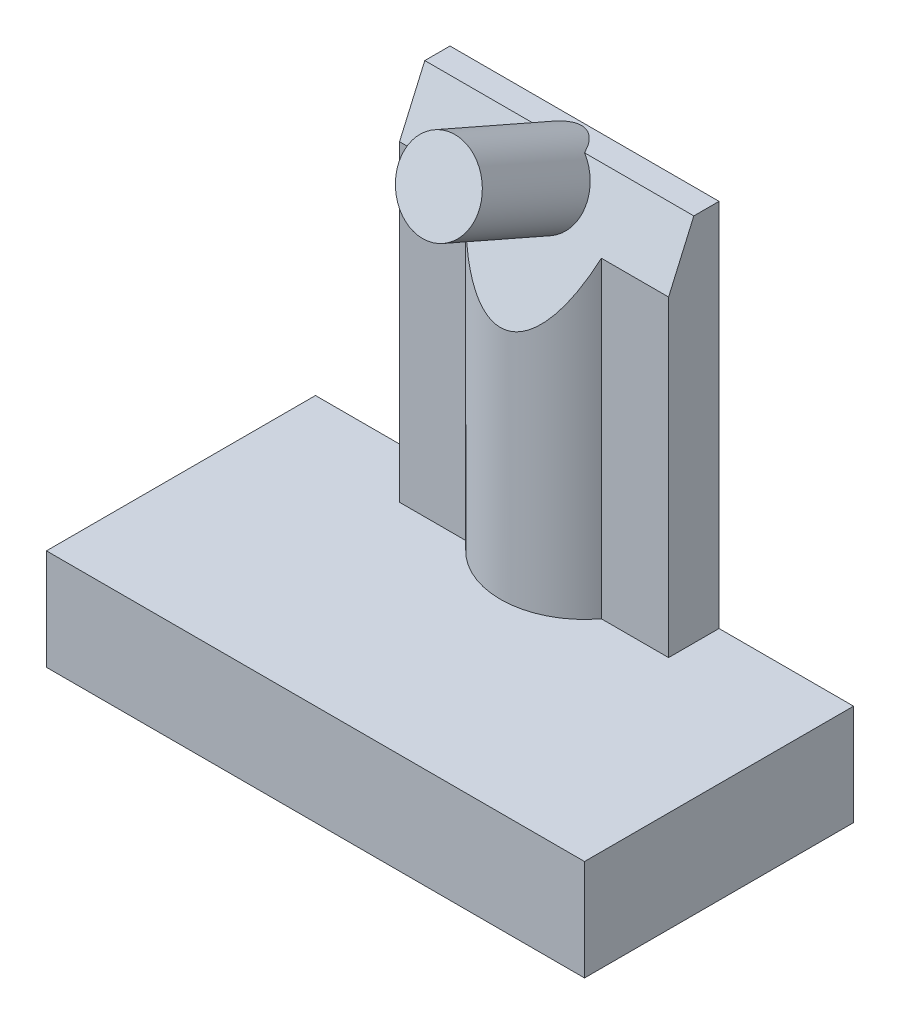
from build123d import *

# Parameters (mm, degrees)
SKETCH1_W                       = 16
SKETCH1_H                       = 8
BOSS_EXTRUDE1_DEPTH             = 3
SHELL1_T                        = -1
SKETCH2_R                       = 1.5
SKETCH2_R_2                     = 0.8
BOSS_EXTRUDE2_DEPTH             = 2
BOSS_EXTRUDE3_DEPTH             = 11
CUT_EXTRUDE1_DEPTH              = 19.867962264
BOSS_EXTRUDE4_REACH             = 18.513
SKETCH5_R                       = 1.2
BOSS_EXTRUDE4_DIRECTION_2_DEPTH = 3.5


with BuildPart() as part:
    # Sketch1 → Boss-Extrude1 (new body)
    with BuildSketch(Plane(origin=(0, 0, 0), x_dir=(1, 0, 0), z_dir=(0, 1, 0))):
        Rectangle(SKETCH1_W, SKETCH1_H)
    extrude(amount=BOSS_EXTRUDE1_DEPTH)

    # Shell1
    shell1_openings = [part.faces().sort_by_distance(p)[0] for p in [
        (0, 0, 0),
    ]]
    offset(amount=SHELL1_T, openings=shell1_openings, kind=Kind.INTERSECTION)

    # Sketch2 → Boss-Extrude2 (add)
    with BuildSketch(Plane.XZ.offset(-2)):
        Circle(SKETCH2_R)
        Circle(SKETCH2_R_2, mode=Mode.SUBTRACT)
    extrude(amount=BOSS_EXTRUDE2_DEPTH)

    # Sketch3 → Boss-Extrude3 (add)
    with BuildSketch(Plane(origin=(0, 3, 0), x_dir=(1, 0, 0), z_dir=(0, 1, 0))):
        with BuildLine():
            Line((-4, 4), (4, 4))
            Line((4, 4), (4, 2.5))
            Line((4, 2.5), (2, 2.5))
            ThreePointArc((2, 2.5), (0, 1.5), (-2, 2.5))
            Line((-2, 2.5), (-4, 2.5))
            Line((-4, 2.5), (-4, 4))
        make_face()
    extrude(amount=BOSS_EXTRUDE3_DEPTH)

    # Sketch4 → Cut-Extrude1 (cut, through all)
    with BuildSketch(Plane(origin=(4, 0, 0), x_dir=(0, 0, -1), z_dir=(1, 0, 0))):
        Polygon((3.25, 14), (1.5, 14), (1.5, 10), align=None)
    extrude(amount=-CUT_EXTRUDE1_DEPTH, mode=Mode.SUBTRACT)

    # Sketch5 → Boss-Extrude4 (add, up to next)
    with BuildSketch(Plane(origin=(0, 1.055737705, 2.413114754), x_dir=(1, 0, 0), z_dir=(0, 0.40081883401970764, 0.9161573349021892)), mode=Mode.PRIVATE) as boss_extrude4_sk1:
        with Locations((0, 13.193279121)):
            Circle(SKETCH5_R)
    boss_extrude4_tool1 = extrude(boss_extrude4_sk1.sketch, amount=-BOSS_EXTRUDE4_REACH, mode=Mode.PRIVATE) - part.part
    add(boss_extrude4_tool1.solids().sort_by_distance((0, 13.142857, -2.875))[0])

    # Sketch5 → Boss-Extrude4 direction 2 (add)
    with BuildSketch(Plane(origin=(0, 1.055737705, 2.413114754), x_dir=(1, 0, 0), z_dir=(0, 0.40081883401970764, 0.9161573349021892))):
        with Locations((0, 13.193279121)):
            Circle(SKETCH5_R)
    extrude(amount=BOSS_EXTRUDE4_DIRECTION_2_DEPTH)


solid = part.part
